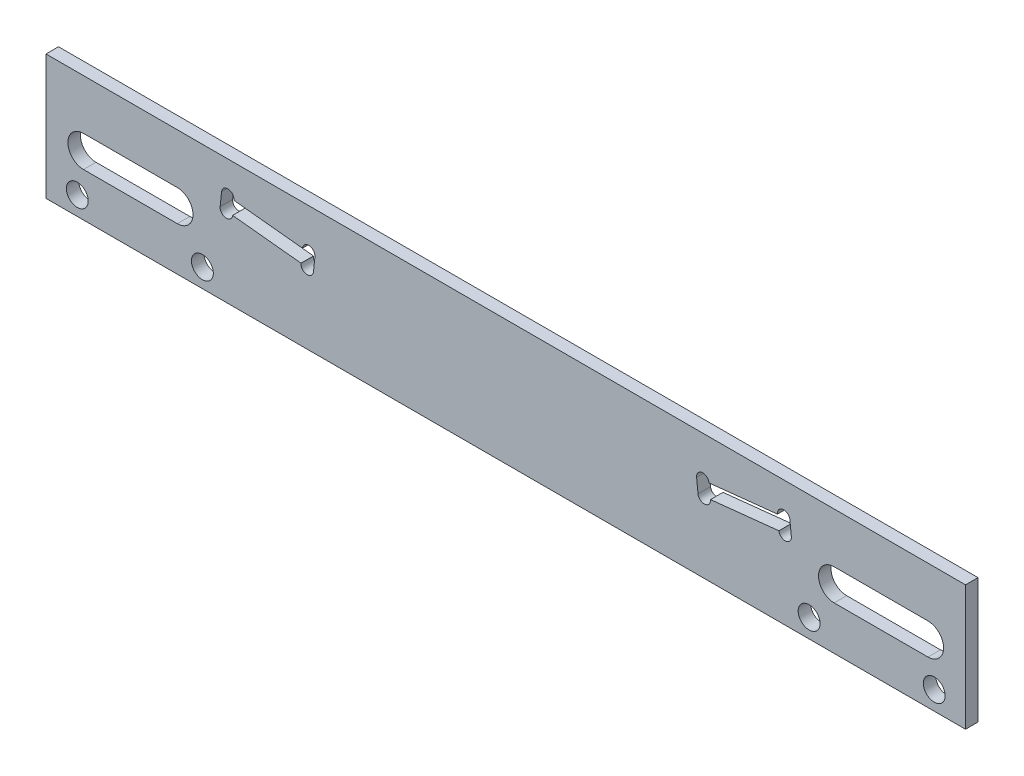
from build123d import *

# Parameters (mm, degrees)
SKETCH_1_W          = 147
SKETCH_1_H          = 20
EXTRUDE_1_DEPTH     = 2
CUT_EXTRUDE_1_DEPTH = 3
SKETCH_3_R          = 1
CUT_EXTRUDE_2_DEPTH = 3
SKETCH_4_R          = 1.75
CUT_EXTRUDE_3_DEPTH = 3
CUT_EXTRUDE_4_DEPTH = 3


with BuildPart() as part:
    # 草图1 → 凸台-拉伸1 (new body)
    with BuildSketch(Plane.XY):
        Rectangle(SKETCH_1_W, SKETCH_1_H)
    extrude(amount=EXTRUDE_1_DEPTH)

    # 草图2 → 切除-拉伸1 (cut)
    with BuildSketch(Plane.XY.offset(2)):
        Polygon((30.510902349, 3.396971992), (30.740864968, 1.209023822), (45.658693398, 2.776950771), (45.428730779, 4.964898941), align=None)
    cut_extrude_1 = extrude(amount=-CUT_EXTRUDE_1_DEPTH, mode=Mode.SUBTRACT)

    # 草图3 → 切除-拉伸2 (cut, through all)
    with BuildSketch(Plane.XY.offset(2)):
        with Locations((31.505424244, 3.501500455)):
            Circle(SKETCH_3_R)
        with Locations((31.735386863, 1.313552286)):
            Circle(SKETCH_3_R)
        with Locations((44.434208884, 4.860370478)):
            Circle(SKETCH_3_R)
        with Locations((44.664171503, 2.672422308)):
            Circle(SKETCH_3_R)
    cut_extrude_2 = extrude(amount=-CUT_EXTRUDE_2_DEPTH, mode=Mode.SUBTRACT)

    # 镜向1: 切除-拉伸1, 切除-拉伸2 across plane
    add(cut_extrude_1.mirror(Plane(origin=(0, 0, 0), x_dir=(0, 0, 1), z_dir=(1, 0, 0))), mode=Mode.SUBTRACT)
    add(cut_extrude_2.mirror(Plane(origin=(0, 0, 0), x_dir=(0, 0, 1), z_dir=(1, 0, 0))), mode=Mode.SUBTRACT)

    # 草图4 → 切除-拉伸3 (cut, through all)
    with BuildSketch(Plane(origin=(0, 0, 0), x_dir=(-1, 0, 0), z_dir=(0, 0, -1))):
        with Locations((68.5, -7)):
            Circle(SKETCH_4_R)
        with Locations((48.5, -7)):
            Circle(SKETCH_4_R)
        with Locations((-48.5, -7)):
            Circle(SKETCH_4_R)
        with Locations((-68.5, -7)):
            Circle(SKETCH_4_R)
    extrude(amount=-CUT_EXTRUDE_3_DEPTH, mode=Mode.SUBTRACT)

    # 草图5 → 切除-拉伸4 (cut, through all)
    with BuildSketch(Plane.XY.offset(2)):
        with BuildLine():
            Line((52.5, 2), (67.5, 2))
            ThreePointArc((67.5, 2), (70, -0.5), (67.5, -3))
            Line((67.5, -3), (52.5, -3))
            ThreePointArc((52.5, -3), (50, -0.5), (52.5, 2))
        make_face()
    cut_extrude_4 = extrude(amount=-CUT_EXTRUDE_4_DEPTH, mode=Mode.SUBTRACT)

    # 镜向2: 切除-拉伸4 across plane
    add(cut_extrude_4.mirror(Plane(origin=(0, 0, 0), x_dir=(0, 0, 1), z_dir=(1, 0, 0))), mode=Mode.SUBTRACT)


solid = part.part
